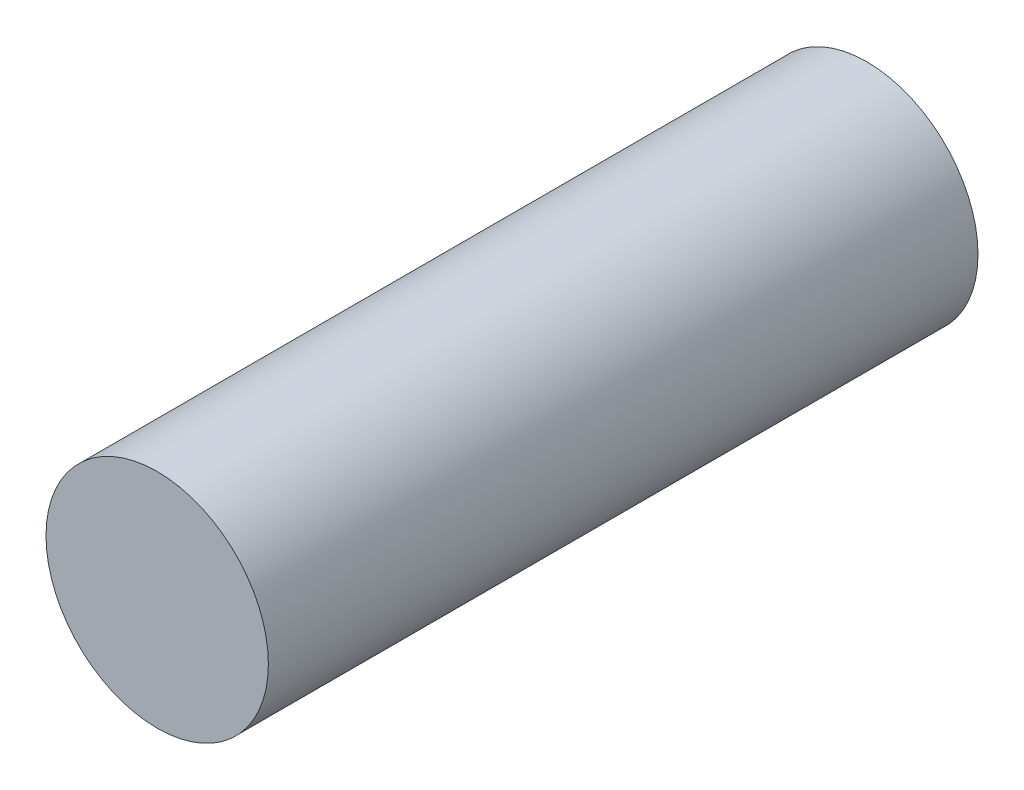
from build123d import *

# Parameters (mm, degrees)
SKIZZE1_R                       = 15.668331021
AUFSATZ_LINEAR_AUSTRAGEN1_DEPTH = 100


with BuildPart() as part:
    # Skizze1 → Aufsatz-Linear austragen1 (new body)
    with BuildSketch(Plane.XY):
        Circle(SKIZZE1_R)
    extrude(amount=AUFSATZ_LINEAR_AUSTRAGEN1_DEPTH)


solid = part.part
